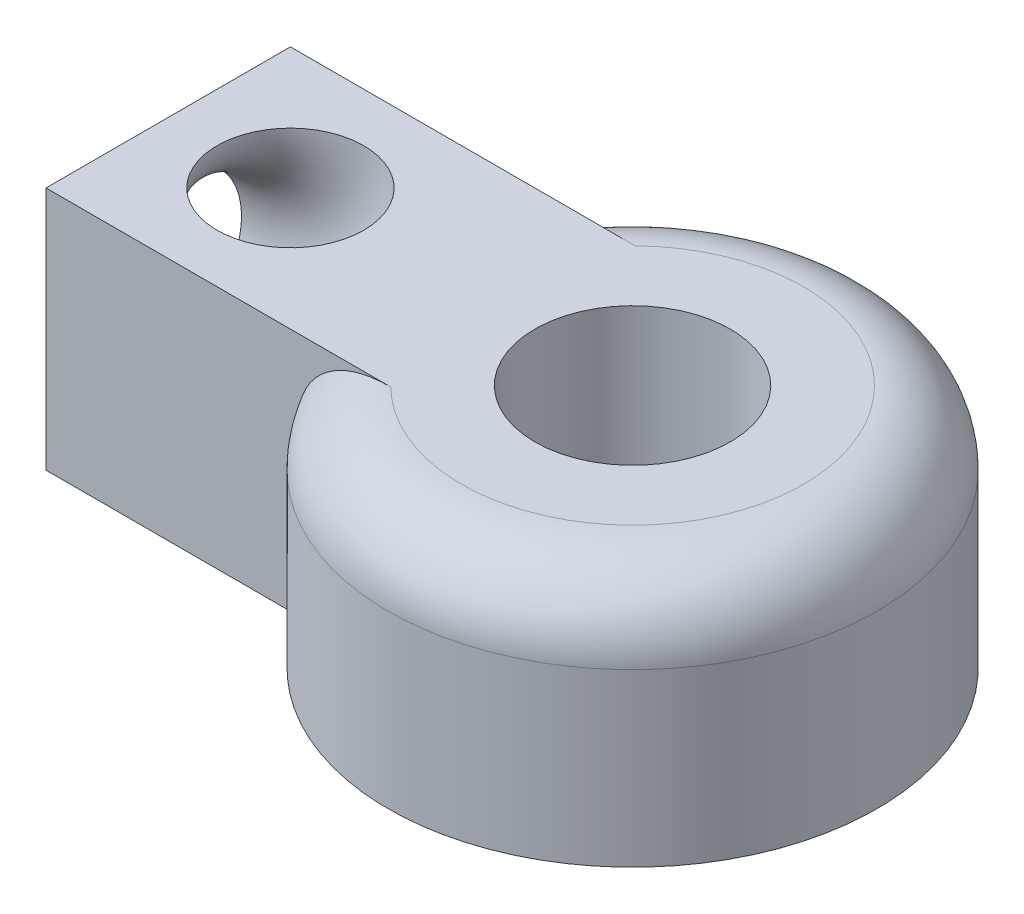
from build123d import *

# Parameters (mm, degrees)
SKETCH1_R           = 10
SKETCH1_R_2         = 4
BOSS_EXTRUDE1_DEPTH = 10
BOSS_EXTRUDE2_DEPTH = 10
SKETCH3_R           = 3
FILLET1_R           = 3


with BuildPart() as part:
    # Sketch1 → Boss-Extrude1 (new body)
    with BuildSketch(Plane(origin=(0, 0, 0), x_dir=(1, 0, 0), z_dir=(0, 1, 0))):
        Circle(SKETCH1_R)
        Circle(SKETCH1_R_2, mode=Mode.SUBTRACT)
    extrude(amount=BOSS_EXTRUDE1_DEPTH)

    # Sketch2 → Boss-Extrude2 (add)
    with BuildSketch(Plane(origin=(0, 10, 0), x_dir=(1, 0, 0), z_dir=(0, 1, 0))):
        with BuildLine():
            Line((-19, -5), (-8.660254038, -5))
            ThreePointArc((-8.660254038, -5), (-10, 0), (-8.660254038, 5))
            Line((-8.660254038, 5), (-19, 5))
            Line((-19, 5), (-19, -5))
        make_face()
    extrude(amount=-BOSS_EXTRUDE2_DEPTH)

    # Sketch3 → Cut-Revolve1 (revolve, cut)
    with BuildSketch(Plane.ZY.offset(19)):
        with Locations((0, 5)):
            Circle(SKETCH3_R)
    revolve(axis=Axis((-19, 10, 5), (0, 0, -1)), mode=Mode.SUBTRACT)

    # Fillet1
    fillet1_edges = [part.edges().sort_by_distance(p)[0] for p in [
        (10, 10, 0),
    ]]
    fillet(fillet1_edges, radius=FILLET1_R)


solid = part.part
